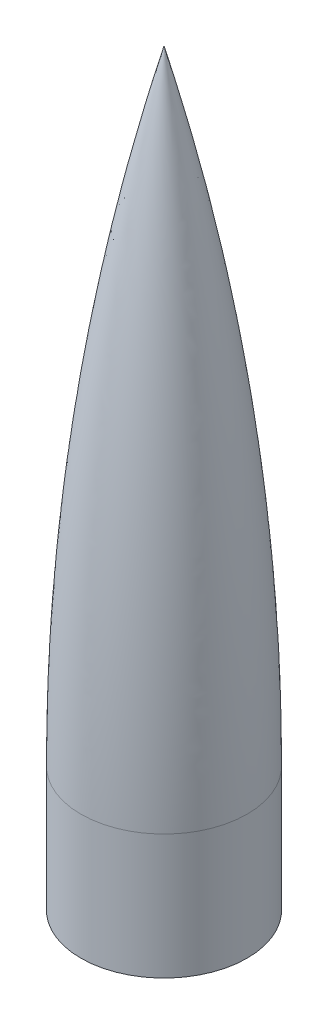
from build123d import *


with BuildPart() as part:
    # Sketch1 → Revolve1 (revolve)
    with BuildSketch(Plane.XY):
        with BuildLine():
            Line((50.8, 0), (50.8, 76.2))
            ThreePointArc((50.8, 76.2), (38.044051778, 268.38587357), (0, 457.2))
            Line((0, 457.2), (0, 452.323745462))
            ThreePointArc((0, 452.323745462), (37.094279103, 265.885458589), (49.53, 76.2))
            Line((49.53, 76.2), (49.53, 0))
            Line((49.53, 0), (50.8, 0))
        make_face()
    revolve(axis=Axis((0, 0, 0), (0, 1, 0)))


solid = part.part
